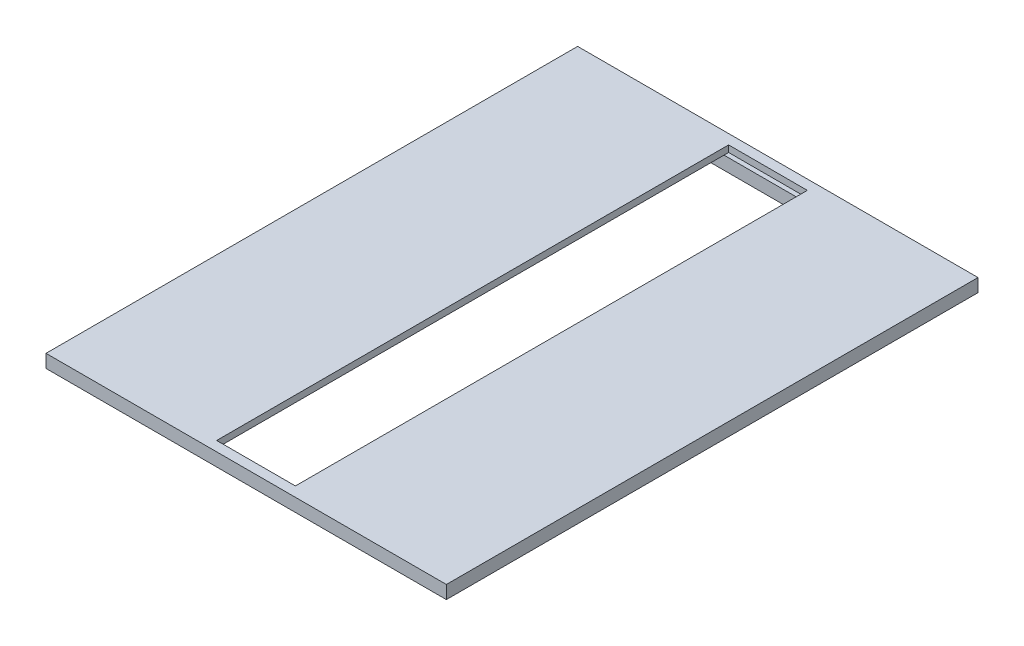
from build123d import *

# Parameters (mm, degrees)
SKETCH1_W           = 152.5
SKETCH1_H           = 202.5
BOSS_EXTRUDE1_DEPTH = 5
SKETCH3_W           = 151.5
SKETCH3_H           = 201.5
CUT_EXTRUDE1_DEPTH  = 2.5
SKETCH5_W           = 146.5
SKETCH5_H           = 196.5
SKETCH5_W_2         = 141.5
SKETCH5_H_2         = 191.5
BOSS_EXTRUDE3_DEPTH = 5
SKETCH6_W           = 30
SKETCH6_H           = 195
CUT_EXTRUDE4_DEPTH  = 2.5
SKETCH7_W           = 5
SKETCH7_H           = 185.5
BOSS_EXTRUDE5_DEPTH = 3


with BuildPart() as part:
    # Sketch1 → Boss-Extrude1 (new body)
    with BuildSketch(Plane(origin=(0, 0, 0), x_dir=(1, 0, 0), z_dir=(0, 1, 0))):
        Rectangle(SKETCH1_W, SKETCH1_H)
    extrude(amount=-BOSS_EXTRUDE1_DEPTH)

    # Sketch3 → Cut-Extrude1 (cut)
    with BuildSketch(Plane.XZ.offset(5)):
        Rectangle(SKETCH3_W, SKETCH3_H)
    extrude(amount=-CUT_EXTRUDE1_DEPTH, mode=Mode.SUBTRACT)

    # Sketch5 → Boss-Extrude3 (add)
    with BuildSketch(Plane.XZ.offset(2.5)):
        Rectangle(SKETCH5_W, SKETCH5_H)
        Rectangle(SKETCH5_W_2, SKETCH5_H_2, mode=Mode.SUBTRACT)
    extrude(amount=BOSS_EXTRUDE3_DEPTH)

    # Sketch6 → Cut-Extrude4 (cut)
    with BuildSketch(Plane(origin=(0, 0, 0), x_dir=(1, 0, 0), z_dir=(0, 1, 0))):
        Rectangle(SKETCH6_W, SKETCH6_H)
    extrude(amount=-CUT_EXTRUDE4_DEPTH, mode=Mode.SUBTRACT)

    # Sketch7 → Boss-Extrude5 (add)
    with BuildSketch(Plane.XZ.offset(2.5)):
        with Locations((-22.5, 0)):
            Rectangle(SKETCH7_W, SKETCH7_H)
        with Locations((22.5, 0)):
            Rectangle(SKETCH7_W, SKETCH7_H)
    extrude(amount=BOSS_EXTRUDE5_DEPTH)


solid = part.part
